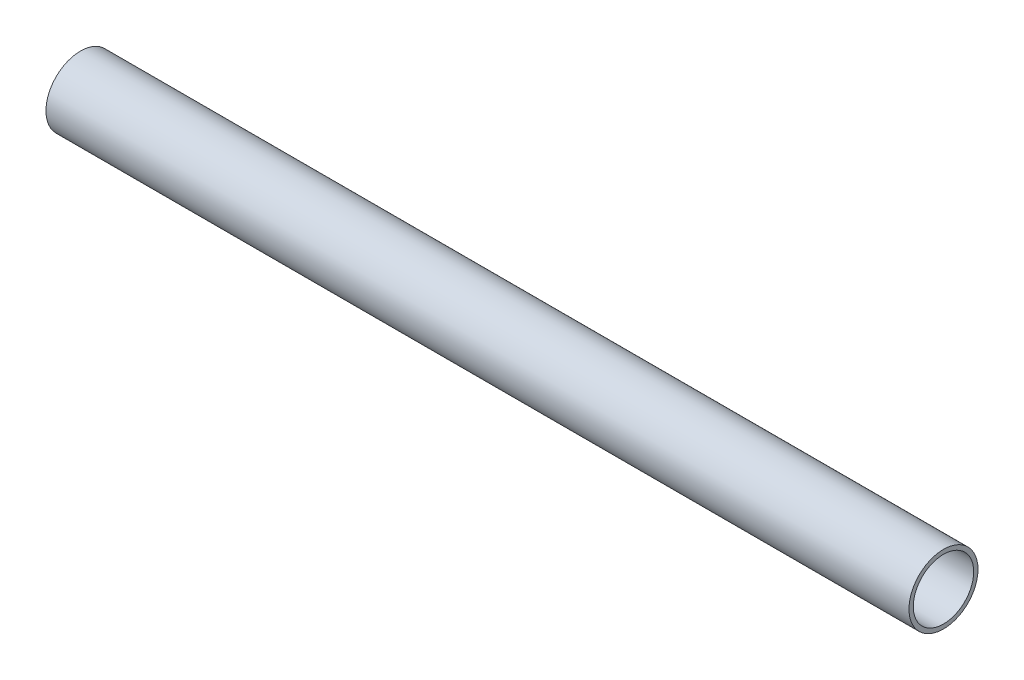
from build123d import *

# Parameters (mm, degrees)
SKETCH_1_R      = 20
SKETCH_1_R_2    = 17.5
EXTRUDE_1_DEPTH = 500


with BuildPart() as part:
    # 草图1 → 凸台-拉伸1 (new body)
    with BuildSketch(Plane(origin=(0, 0, 0), x_dir=(0, 0, -1), z_dir=(1, 0, 0))):
        Circle(SKETCH_1_R)
        Circle(SKETCH_1_R_2, mode=Mode.SUBTRACT)
    extrude(amount=EXTRUDE_1_DEPTH)


solid = part.part
